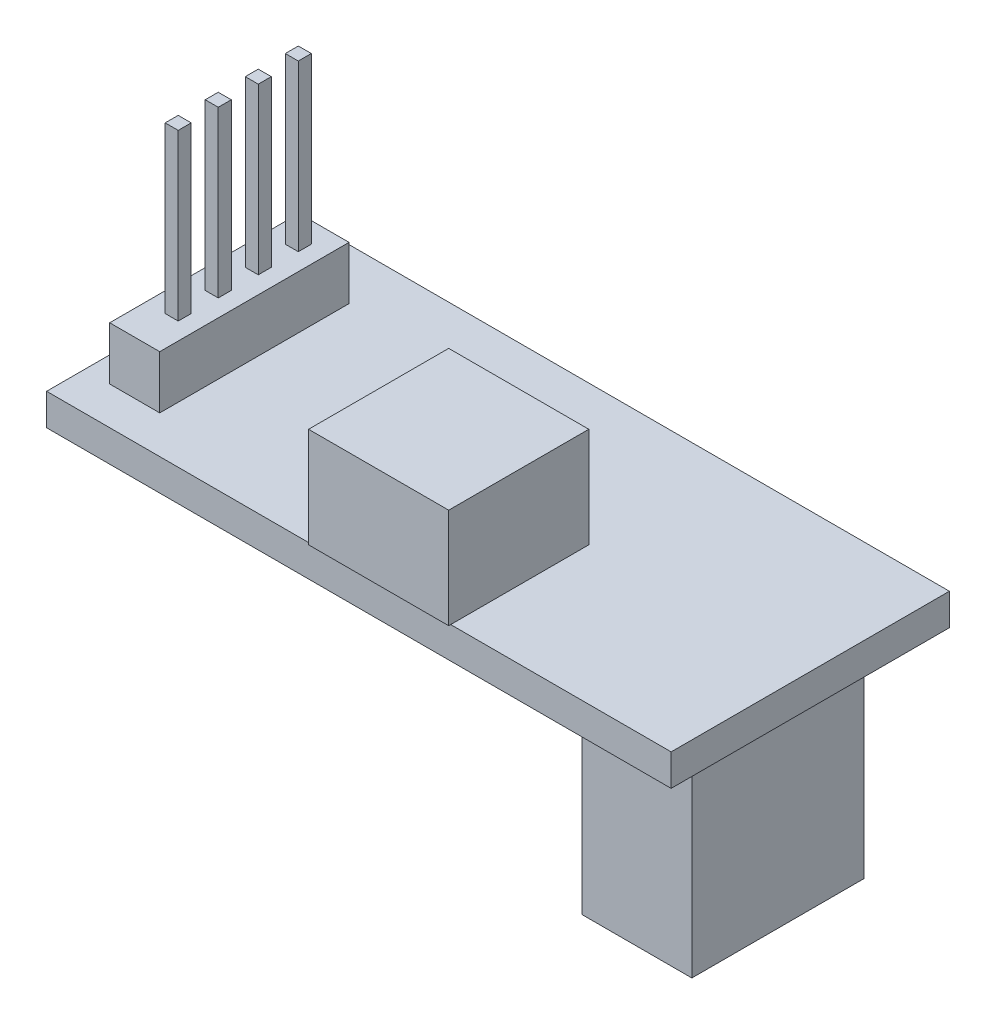
from build123d import *

# Parameters (mm, degrees)
ESBO_O1_W                = 31.2
ESBO_O1_H                = 13.9
RESSALTO_EXTRUS_O1_DEPTH = 1.58
ESBO_O2_W                = 7
ESBO_O2_H                = 6.9
ESBO_O2_H_2              = 0.1
RESSALTO_EXTRUS_O2_DEPTH = 5
RESSALTO_EXTRUS_O3_DEPTH = 10.5
CHANFRO1_SIZE            = 0.5
ESBO_O4_W                = 2.5
ESBO_O4_H                = 9.457135355
RESSALTO_EXTRUS_O4_DEPTH = 2.65
ESBO_O5_W                = 0.65
ESBO_O5_H                = 0.65
RESSALTO_EXTRUS_O5_DEPTH = 8.25
PADR_O_LINEAR1_COUNT     = 4
PADR_O_LINEAR1_PITCH     = 2


with BuildPart() as part:
    # Esboço1 → Ressalto-extrusão1 (new body)
    with BuildSketch(Plane(origin=(0, 0, 0), x_dir=(1, 0, 0), z_dir=(0, 1, 0))):
        Rectangle(ESBO_O1_W, ESBO_O1_H)
    extrude(amount=RESSALTO_EXTRUS_O1_DEPTH)

    # Esboço2 → Ressalto-extrusão2 (add)
    with BuildSketch(Plane(origin=(0, 1.58, 0), x_dir=(1, 0, 0), z_dir=(0, 1, 0))):
        with Locations((1.086462839, -3.5)):
            Rectangle(ESBO_O2_W, ESBO_O2_H)
        with Locations((1.086462839, -7)):
            Rectangle(ESBO_O2_W, ESBO_O2_H_2)
    extrude(amount=RESSALTO_EXTRUS_O2_DEPTH)

    # Esboço3 → Ressalto-extrusão3 (add)
    with BuildSketch(Plane.XZ):
        Polygon((12.918626435, -5.363327787), (14.320868257, -3.961085964), (14.320868257, 4.636672213), (8.820868257, 4.636672213), (8.820868257, -3.961085964), (9.855714298, -5.363327787), align=None)
    extrude(amount=RESSALTO_EXTRUS_O3_DEPTH)

    # Chanfro1
    chanfro1_edges = [part.edges().sort_by_distance(p)[0] for p in [
        (11.570868257, -10.5, 4.636672213),
        (8.820868257, -10.5, 0.337793125),
        (9.338291278, -10.5, -4.662206875),
        (11.387170366, -10.5, -5.363327787),
        (13.619747346, -10.5, -4.662206875),
        (14.320868257, -10.5, 0.337793125),
    ]]
    chamfer(chanfro1_edges, length=CHANFRO1_SIZE)

    # Esboço4 → Ressalto-extrusão4 (add)
    with BuildSketch(Plane(origin=(0, 1.58, 0), x_dir=(1, 0, 0), z_dir=(0, 1, 0))):
        with Locations((-13.088241827, -0.331483756)):
            Rectangle(ESBO_O4_W, ESBO_O4_H)
    extrude(amount=RESSALTO_EXTRUS_O4_DEPTH)

    # Esboço5 → Ressalto-extrusão5 (add)
    with BuildSketch(Plane(origin=(0, 4.23, 0), x_dir=(1, 0, 0), z_dir=(0, 1, 0))):
        with Locations((-13.025924603, 3.050020292)):
            Rectangle(ESBO_O5_W, ESBO_O5_H)
    ressalto_extrus_o5 = extrude(amount=RESSALTO_EXTRUS_O5_DEPTH)

    # Padrão linear1: Ressalto-extrusão5 ×4
    with Locations(*[(0, 0, i * PADR_O_LINEAR1_PITCH) for i in range(1, PADR_O_LINEAR1_COUNT)]):
        add(ressalto_extrus_o5)


solid = part.part
